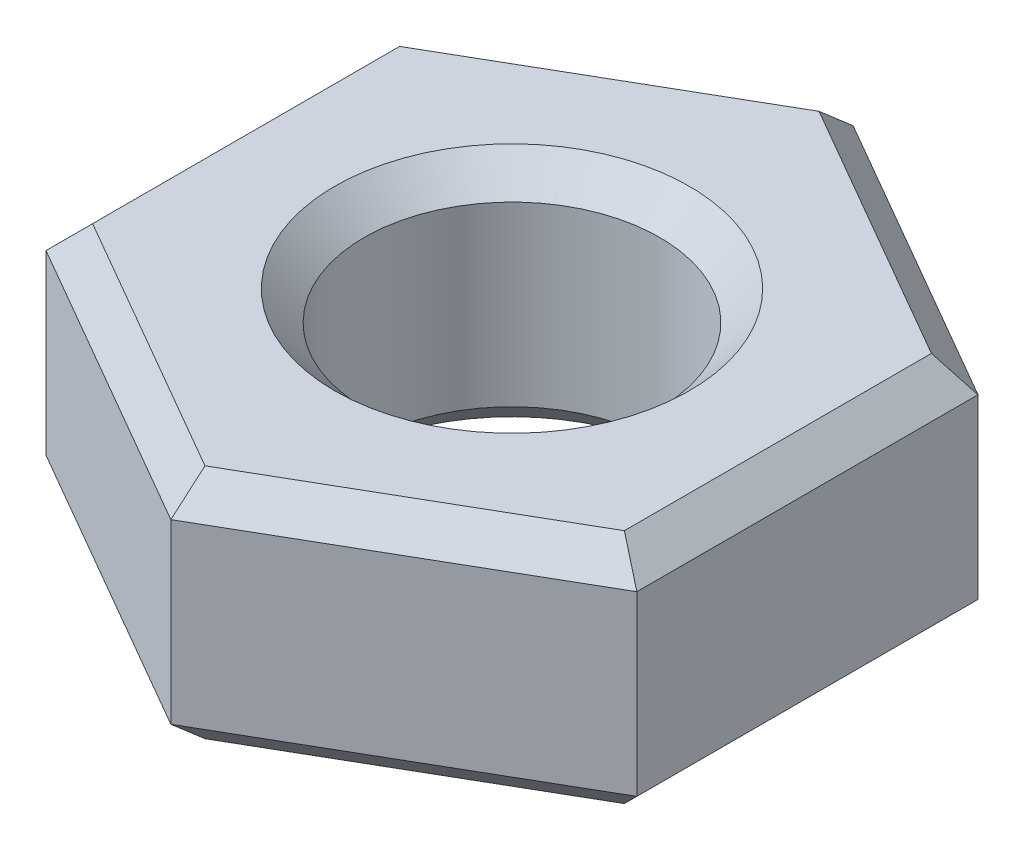
from build123d import *

# Parameters (mm, degrees)
SKETCH1_R           = 1.25
BOSS_EXTRUDE1_DEPTH = 2
CHAMFER1_SIZE       = 0.25


with BuildPart() as part:
    # Sketch1 → Boss-Extrude1 (new body)
    with BuildSketch(Plane(origin=(0, 0, 0), x_dir=(1, 0, 0), z_dir=(0, 1, 0))):
        Polygon((0, -2.886751346), (2.5, -1.443375673), (2.5, 1.443375673), (0, 2.886751346), (-2.5, 1.443375673), (-2.5, -1.443375673), align=None)
        Circle(SKETCH1_R, mode=Mode.SUBTRACT)
    extrude(amount=BOSS_EXTRUDE1_DEPTH)

    # Chamfer1
    chamfer1_edges = [part.edges().sort_by_distance(p)[0] for p in [
        (2.5, 2, 0),
        (1.25, 2, -2.165063509),
        (-1.25, 0, 0),
        (-1.25, 2, 0),
        (-1.25, 2, -2.165063509),
        (-2.5, 2, 0),
        (-1.25, 2, 2.165063509),
        (-2.5, 0, 0),
        (-1.25, 0, -2.165063509),
        (1.25, 0, -2.165063509),
        (2.5, 0, 0),
        (1.25, 0, 2.165063509),
        (-1.25, 0, 2.165063509),
        (1.25, 2, 2.165063509),
    ]]
    chamfer(chamfer1_edges, length=CHAMFER1_SIZE)


solid = part.part
